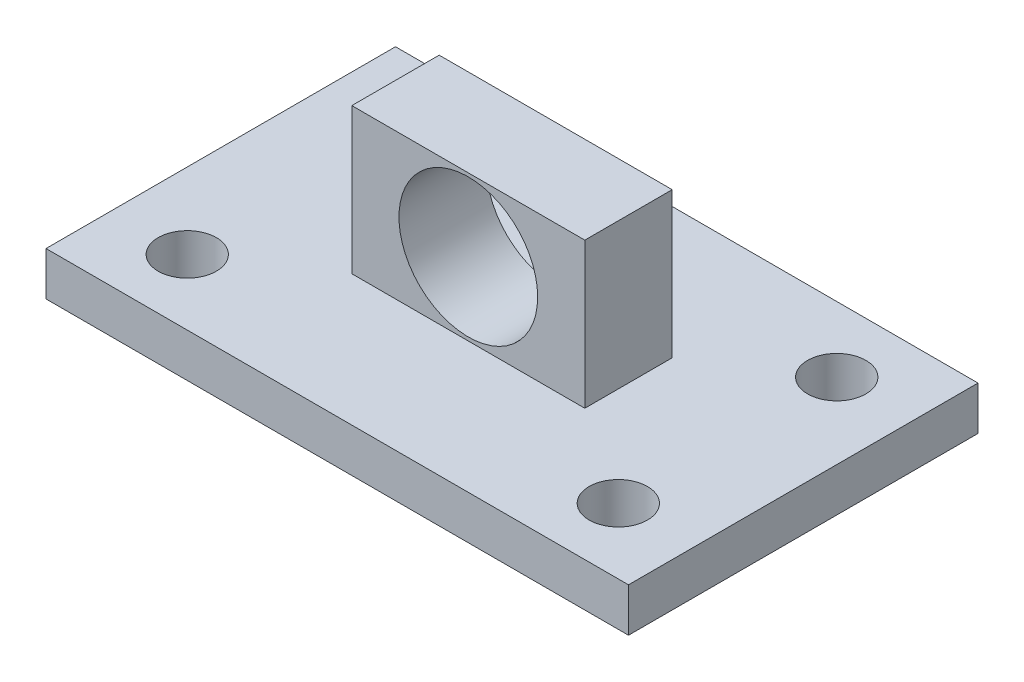
from build123d import *

# Parameters (mm, degrees)
SKETCH_1_W          = 40
SKETCH_1_H          = 24
SKETCH_1_R          = 2
EXTRUDE_1_DEPTH     = 3
SKETCH_2_W          = 16
SKETCH_2_H          = 6
EXTRUDE_2_DEPTH     = 10
SKETCH_3_R          = 4.7625
CUT_EXTRUDE_1_DEPTH = 10


with BuildPart() as part:
    # 草图1 → 凸台-拉伸1 (new body)
    with BuildSketch(Plane(origin=(0, 0, 0), x_dir=(1, 0, 0), z_dir=(0, 1, 0))):
        Rectangle(SKETCH_1_W, SKETCH_1_H)
        with Locations((-14.8, -7.5)):
            Circle(SKETCH_1_R, mode=Mode.SUBTRACT)
        with Locations((14.8, -7.5)):
            Circle(SKETCH_1_R, mode=Mode.SUBTRACT)
        with Locations((-14.8, 7.5)):
            Circle(SKETCH_1_R, mode=Mode.SUBTRACT)
        with Locations((14.8, 7.5)):
            Circle(SKETCH_1_R, mode=Mode.SUBTRACT)
    extrude(amount=EXTRUDE_1_DEPTH)

    # 草图2 → 凸台-拉伸2 (add)
    with BuildSketch(Plane(origin=(0, 3, 0), x_dir=(1, 0, 0), z_dir=(0, 1, 0))):
        Rectangle(SKETCH_2_W, SKETCH_2_H)
    extrude(amount=EXTRUDE_2_DEPTH)

    # 草图3 → 切除-拉伸1 (cut)
    with BuildSketch(Plane.XY.offset(3)):
        with Locations((0, 8)):
            Circle(SKETCH_3_R)
    extrude(amount=-CUT_EXTRUDE_1_DEPTH, mode=Mode.SUBTRACT)


solid = part.part
